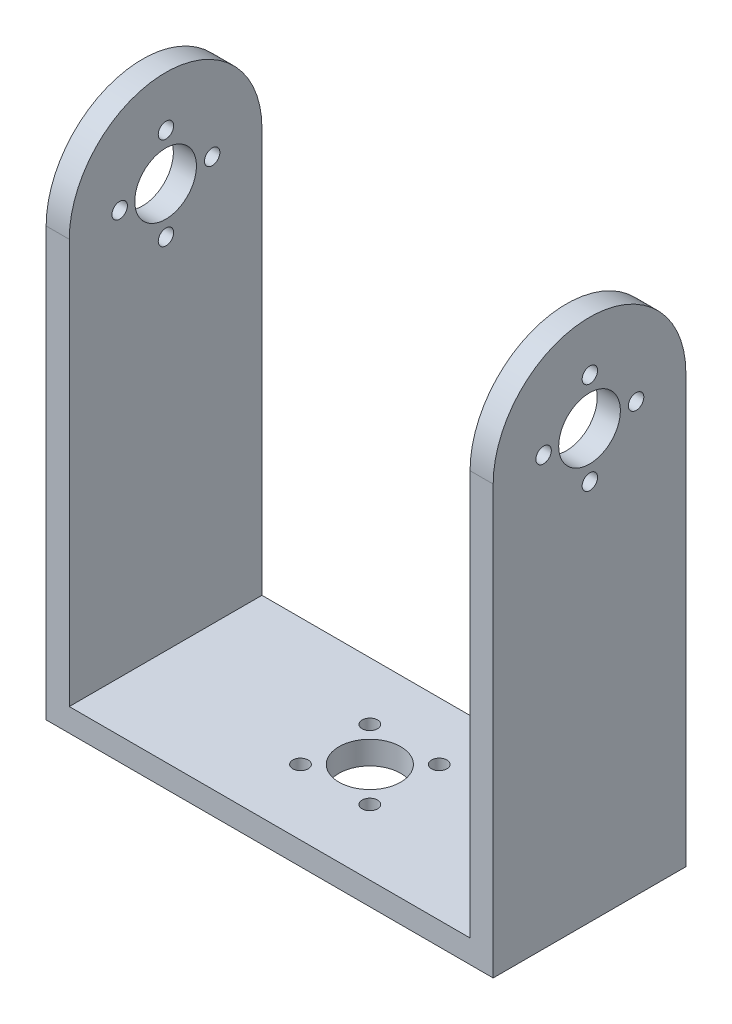
from build123d import *

# Parameters (mm, degrees)
SKETCH1_W               = 58
SKETCH1_H               = 25
BOSS_EXTRUDE1_DEPTH     = 3
SKETCH2_W               = 3
SKETCH2_H               = 25
BOSS_EXTRUDE2_DEPTH     = 65
CUT_EXTRUDE1_DEPTH      = 65
SKETCH4_R               = 4
CUT_EXTRUDE2_DEPTH      = 65
SKETCH5_R               = 1
CUT_EXTRUDE3_DEPTH      = 56
CUT_EXTRUDE3_DEPTH_BACK = 4
CUT_EXTRUDE5_REACH      = 70
SKETCH7_R               = 4
SKETCH7_R_2             = 1


with BuildPart() as part:
    # Sketch1 → Boss-Extrude1 (new body)
    with BuildSketch(Plane(origin=(0, 0, 0), x_dir=(1, 0, 0), z_dir=(0, 1, 0))):
        with Locations((29, 12.5)):
            Rectangle(SKETCH1_W, SKETCH1_H)
    extrude(amount=BOSS_EXTRUDE1_DEPTH)

    # Sketch2 → Boss-Extrude2 (add)
    with BuildSketch(Plane(origin=(0, 3, 0), x_dir=(1, 0, 0), z_dir=(0, 1, 0))):
        with Locations((56.5, 12.5)):
            Rectangle(SKETCH2_W, SKETCH2_H)
        with Locations((1.5, 12.5)):
            Rectangle(SKETCH2_W, SKETCH2_H)
    extrude(amount=BOSS_EXTRUDE2_DEPTH)

    # Sketch3 → Cut-Extrude1 (cut)
    with BuildSketch(Plane.ZY):
        with BuildLine():
            Line((-25, 68), (-25, 55.5))
            ThreePointArc((-25, 55.5), (-21.338834765, 64.338834765), (-12.5, 68))
            Line((-12.5, 68), (-25, 68))
        make_face()
        with BuildLine():
            Line((0, 68), (-12.5, 68))
            ThreePointArc((-12.5, 68), (-3.661165235, 64.338834765), (0, 55.5))
            Line((0, 55.5), (0, 68))
        make_face()
    extrude(amount=-CUT_EXTRUDE1_DEPTH, mode=Mode.SUBTRACT)

    # Sketch4 → Cut-Extrude2 (cut)
    with BuildSketch(Plane.ZY):
        with Locations((-12.5, 55.5)):
            Circle(SKETCH4_R)
    extrude(amount=-CUT_EXTRUDE2_DEPTH, mode=Mode.SUBTRACT)

    # Sketch5 → Cut-Extrude3 (cut, two sides)
    with BuildSketch(Plane(origin=(3, 0, 0), x_dir=(0, 0, -1), z_dir=(1, 0, 0))) as cut_extrude3_sk:
        with Locations((12.543720091, 61.500000009)):
            Circle(SKETCH5_R)
        with Locations((18.543720091, 55.500000009)):
            Circle(SKETCH5_R)
        with Locations((6.543720091, 55.500000009)):
            Circle(SKETCH5_R)
        with Locations((12.543720091, 49.500000009)):
            Circle(SKETCH5_R)
    extrude(amount=CUT_EXTRUDE3_DEPTH, mode=Mode.SUBTRACT)
    extrude(cut_extrude3_sk.sketch, amount=-CUT_EXTRUDE3_DEPTH_BACK, mode=Mode.SUBTRACT)

    # Sketch7 → Cut-Extrude5 (cut, up to next)
    with BuildSketch(Plane(origin=(0, 0, 0), x_dir=(-1, 0, 0), z_dir=(0, -1, 0)), mode=Mode.PRIVATE) as cut_extrude5_sk1:
        with Locations((-29, 13)):
            Circle(SKETCH7_R)
    cut_extrude5_tool1 = extrude(cut_extrude5_sk1.sketch, amount=-CUT_EXTRUDE5_REACH, mode=Mode.PRIVATE) & part.part
    add(cut_extrude5_tool1.solids().sort_by_distance((29, 0, -13))[0], mode=Mode.SUBTRACT)
    # Sketch7 → Cut-Extrude5 (cut, up to next)
    with BuildSketch(Plane(origin=(0, 0, 0), x_dir=(-1, 0, 0), z_dir=(0, -1, 0)), mode=Mode.PRIVATE) as cut_extrude5_sk2:
        with Locations((-24.5, 17.5)):
            Circle(SKETCH7_R_2)
    cut_extrude5_tool2 = extrude(cut_extrude5_sk2.sketch, amount=-CUT_EXTRUDE5_REACH, mode=Mode.PRIVATE) & part.part
    add(cut_extrude5_tool2.solids().sort_by_distance((24.5, 0, -17.5))[0], mode=Mode.SUBTRACT)
    # Sketch7 → Cut-Extrude5 (cut, up to next)
    with BuildSketch(Plane(origin=(0, 0, 0), x_dir=(-1, 0, 0), z_dir=(0, -1, 0)), mode=Mode.PRIVATE) as cut_extrude5_sk3:
        with Locations((-33.5, 17.5)):
            Circle(SKETCH7_R_2)
    cut_extrude5_tool3 = extrude(cut_extrude5_sk3.sketch, amount=-CUT_EXTRUDE5_REACH, mode=Mode.PRIVATE) & part.part
    add(cut_extrude5_tool3.solids().sort_by_distance((33.5, 0, -17.5))[0], mode=Mode.SUBTRACT)
    # Sketch7 → Cut-Extrude5 (cut, up to next)
    with BuildSketch(Plane(origin=(0, 0, 0), x_dir=(-1, 0, 0), z_dir=(0, -1, 0)), mode=Mode.PRIVATE) as cut_extrude5_sk4:
        with Locations((-33.5, 8.5)):
            Circle(SKETCH7_R_2)
    cut_extrude5_tool4 = extrude(cut_extrude5_sk4.sketch, amount=-CUT_EXTRUDE5_REACH, mode=Mode.PRIVATE) & part.part
    add(cut_extrude5_tool4.solids().sort_by_distance((33.5, 0, -8.5))[0], mode=Mode.SUBTRACT)
    # Sketch7 → Cut-Extrude5 (cut, up to next)
    with BuildSketch(Plane(origin=(0, 0, 0), x_dir=(-1, 0, 0), z_dir=(0, -1, 0)), mode=Mode.PRIVATE) as cut_extrude5_sk5:
        with Locations((-24.5, 8.5)):
            Circle(SKETCH7_R_2)
    cut_extrude5_tool5 = extrude(cut_extrude5_sk5.sketch, amount=-CUT_EXTRUDE5_REACH, mode=Mode.PRIVATE) & part.part
    add(cut_extrude5_tool5.solids().sort_by_distance((24.5, 0, -8.5))[0], mode=Mode.SUBTRACT)


solid = part.part
